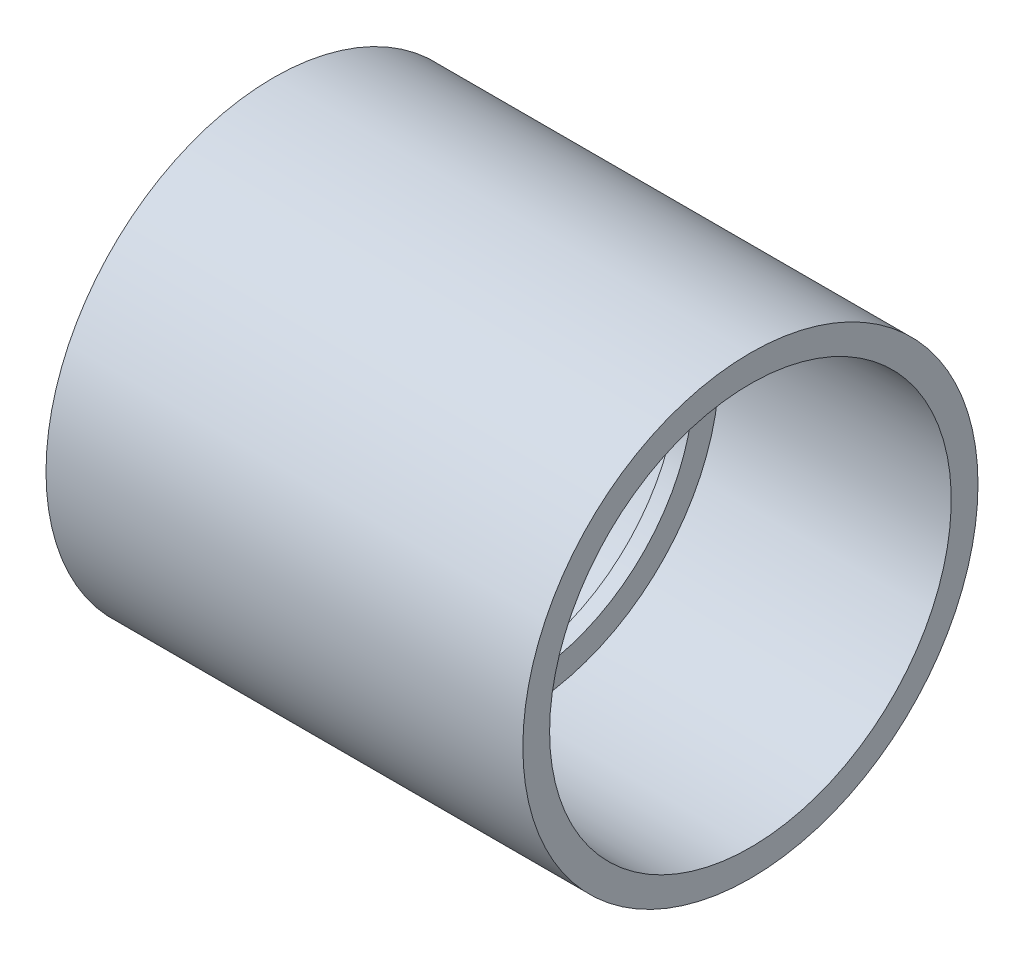
from build123d import *


with BuildPart() as part:
    # Sketch1 → Revolve1 (revolve)
    with BuildSketch(Plane.XY):
        Polygon((-1.1938, -26.2509), (1.1938, -26.2509), (1.1938, -30.0863), (35.9918, -30.3149), (35.9918, -34.3535), (-35.9918, -34.3535), (-35.9918, -30.3149), (-1.1938, -30.0863), align=None)
    revolve(axis=Axis((-35.9918, 0, 0), (1, 0, 0)))


solid = part.part
